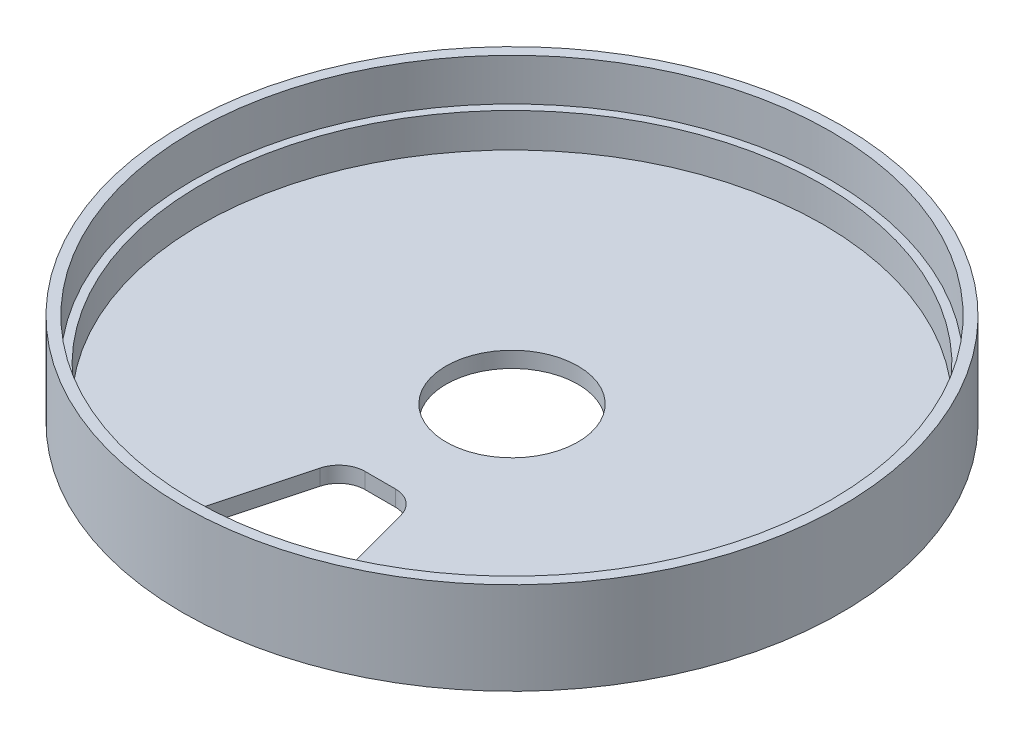
from build123d import *

# Parameters (mm, degrees)
CUT_EXTRUDE1_DEPTH = 18.5
FILLET1_R          = 5


with BuildPart() as part:
    # Sketch2 → Revolve1 (revolve)
    with BuildSketch(Plane.XY):
        Polygon((12.5, 0), (62.5, 0), (62.5, 17.5), (60.5, 17.5), (60.5, 9.5), (59, 9.5), (59, 3), (12.5, 3), align=None)
    revolve(axis=Axis((0, 0, 0), (0, 1, 0)))

    # Sketch3 → Cut-Extrude1 (cut, through all)
    with BuildSketch(Plane.XZ):
        with BuildLine():
            Line((-14.235047481, 53.125920446), (-6.698729811, 25))
            Line((-6.698729811, 25), (6.698729811, 25))
            Line((6.698729811, 25), (14.235047481, 53.125920446))
            ThreePointArc((14.235047481, 53.125920446), (0, 55), (-14.235047481, 53.125920446))
        make_face()
    extrude(amount=-CUT_EXTRUDE1_DEPTH, mode=Mode.SUBTRACT)

    # Fillet1
    fillet1_edges = [part.edges().sort_by_distance(p)[0] for p in [
        (6.698729811, 1.5, 25),
        (-6.698729811, 1.5, 25),
        (-14.235047481, 1.5, 53.125920446),
        (14.235047481, 1.5, 53.125920446),
    ]]
    fillet(fillet1_edges, radius=FILLET1_R)


solid = part.part
